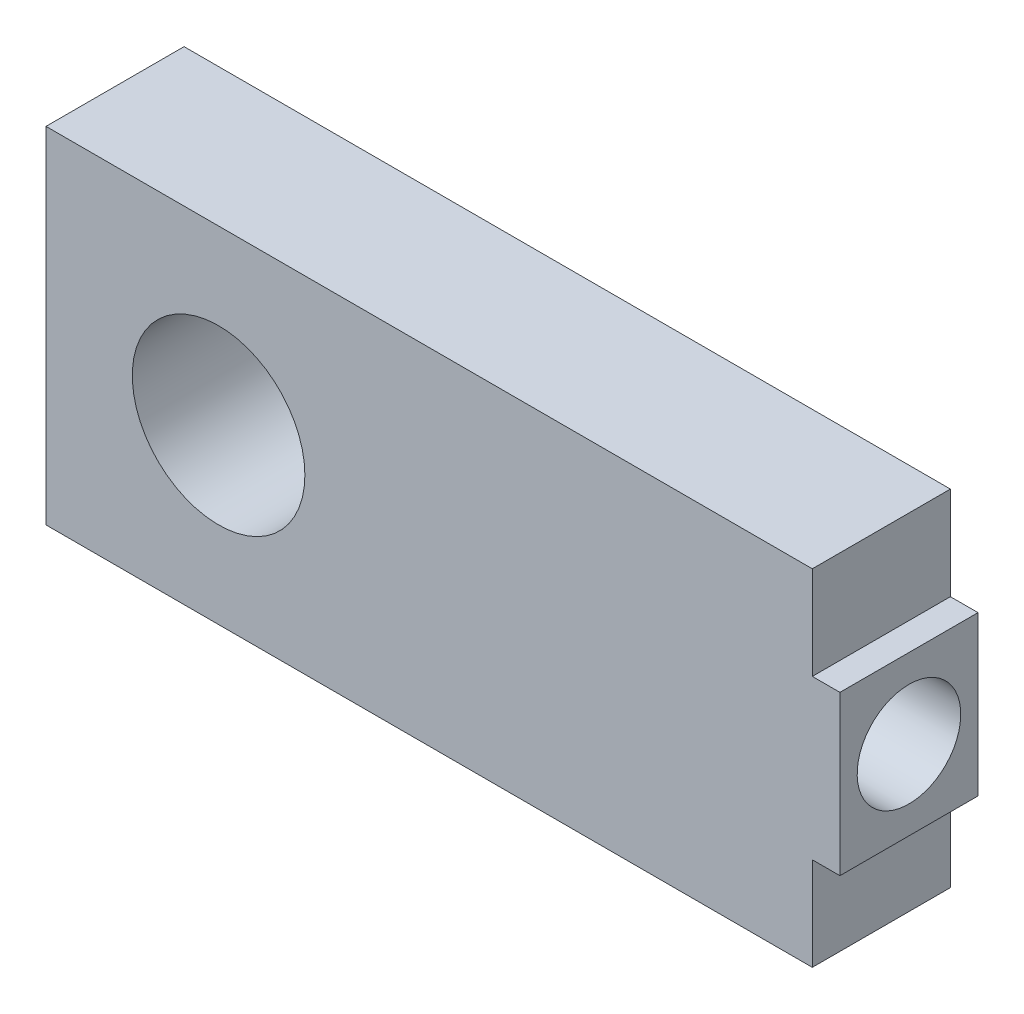
from build123d import *

# Parameters (mm, degrees)
SKETCH1_R           = 635
BOSS_EXTRUDE1_DEPTH = 508
SKETCH2_R           = 381
CUT_EXTRUDE1_DEPTH  = 2540


with BuildPart() as part:
    # Sketch1 → Boss-Extrude1 (new body, symmetric)
    with BuildSketch(Plane.XY):
        Polygon((2819.4, -584.2), (2819.4, -1270), (-2819.4, -1270), (-2819.4, 1270), (2819.4, 1270), (2819.4, 584.2), (3022.6, 584.2), (3022.6, -584.2), align=None)
        with Locations((-1549.4, 0)):
            Circle(SKETCH1_R, mode=Mode.SUBTRACT)
    extrude(amount=BOSS_EXTRUDE1_DEPTH, both=True)

    # Sketch2 → Cut-Extrude1 (cut)
    with BuildSketch(Plane(origin=(3022.6, 0, 0), x_dir=(0, 0, -1), z_dir=(1, 0, 0))):
        Circle(SKETCH2_R)
    extrude(amount=-CUT_EXTRUDE1_DEPTH, mode=Mode.SUBTRACT)


solid = part.part
